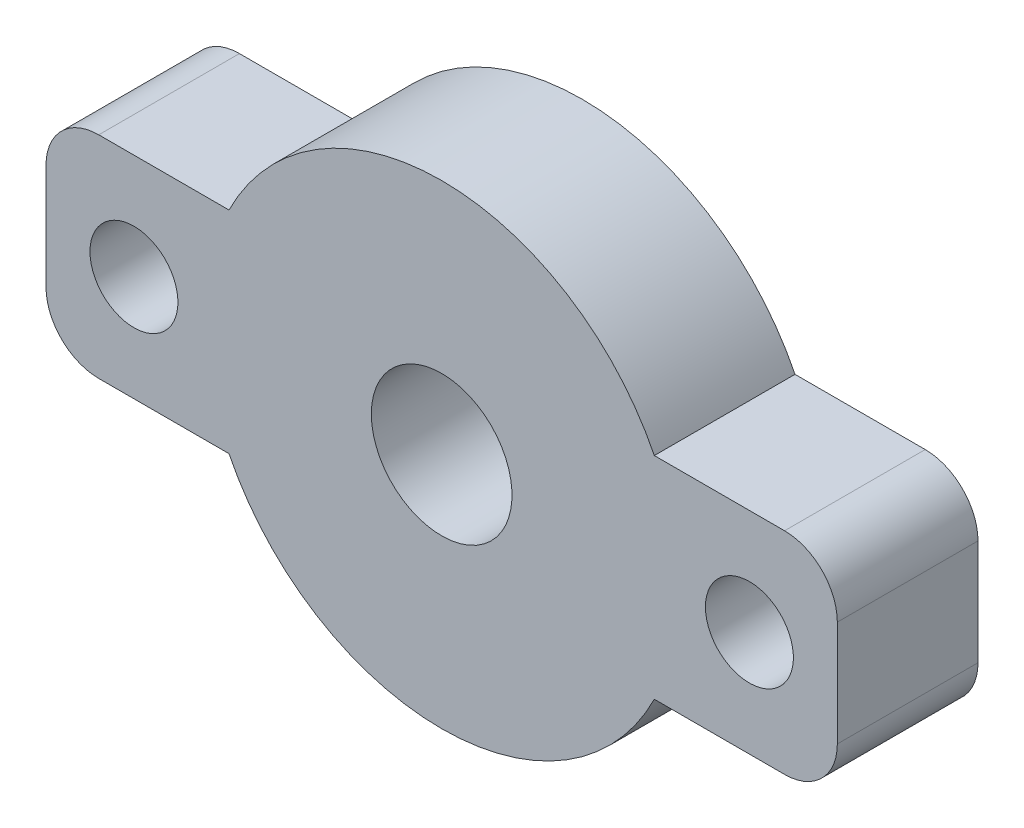
from build123d import *

# Parameters (mm, degrees)
SKETCH_1_R          = 13.5
EXTRUDE_1_DEPTH     = 8
SKETCH_3_W          = 45
SKETCH_3_H          = 12
EXTRUDE_2_DEPTH     = 8
SKETCH_2_R          = 4
CUT_EXTRUDE_1_DEPTH = 8
SKETCH_4_R          = 2.5
CUT_EXTRUDE_2_DEPTH = 9
FILLET_1_R          = 3


with BuildPart() as part:
    # 草图1 → 凸台-拉伸1 (new body)
    with BuildSketch(Plane.XY):
        Circle(SKETCH_1_R)
    extrude(amount=EXTRUDE_1_DEPTH)

    # 草图3 → 凸台-拉伸2 (add)
    with BuildSketch(Plane.XY.offset(8)):
        Rectangle(SKETCH_3_W, SKETCH_3_H)
    extrude(amount=-EXTRUDE_2_DEPTH)

    # 草图2 → 切除-拉伸1 (cut)
    with BuildSketch(Plane(origin=(0, 0, 0), x_dir=(-1, 0, 0), z_dir=(0, 0, -1))):
        Circle(SKETCH_2_R)
    extrude(amount=-CUT_EXTRUDE_1_DEPTH, mode=Mode.SUBTRACT)

    # 草图4 → 切除-拉伸2 (cut, through all)
    with BuildSketch(Plane(origin=(0, 0, 0), x_dir=(-1, 0, 0), z_dir=(0, 0, -1))):
        with Locations((-17.5, 0)):
            Circle(SKETCH_4_R)
        with Locations((17.5, 0)):
            Circle(SKETCH_4_R)
    extrude(amount=-CUT_EXTRUDE_2_DEPTH, mode=Mode.SUBTRACT)

    # 圆角1
    fillet_1_edges = [part.edges().sort_by_distance(p)[0] for p in [
        (-22.5, 6, 4),
        (22.5, -6, 4),
        (-22.5, -6, 4),
        (22.5, 6, 4),
    ]]
    fillet(fillet_1_edges, radius=FILLET_1_R)


solid = part.part
